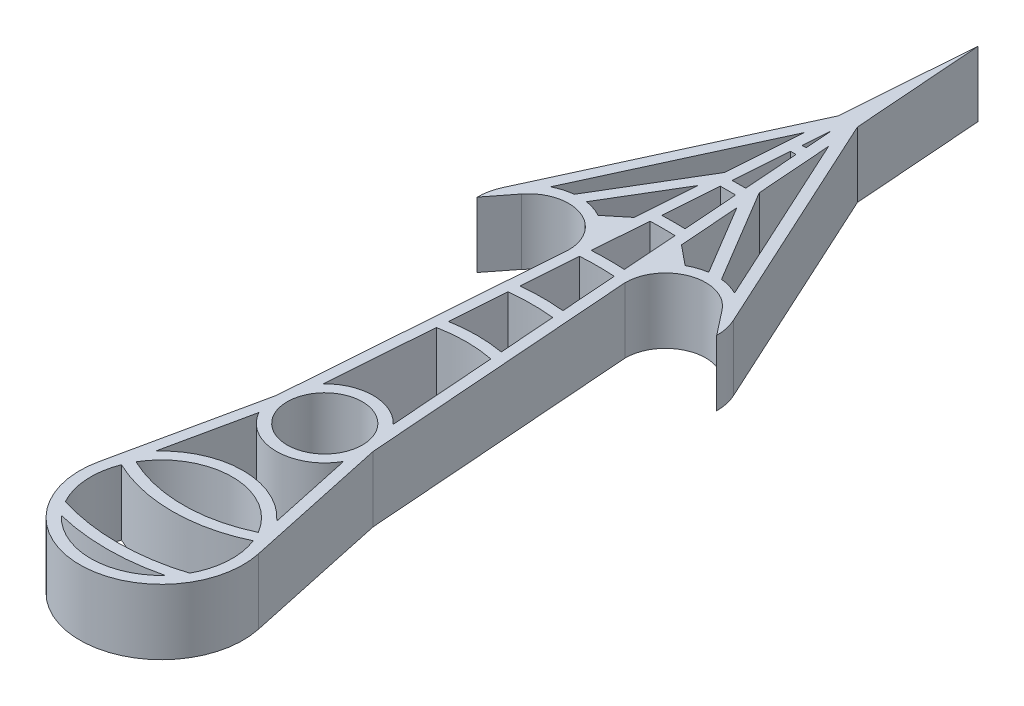
from build123d import *

# Parameters (mm, degrees)
SKETCH1_R           = 3.45
SKETCH1_R_2         = 6.5
BOSS_EXTRUDE1_DEPTH = 6
BOSS_EXTRUDE2_DEPTH = 6
BOSS_EXTRUDE4_DEPTH = 6


with BuildPart() as part:
    # Sketch1 → Boss-Extrude1 (new body)
    with BuildSketch(Plane(origin=(0, 0, 0), x_dir=(1, 0, 0), z_dir=(0, 1, 0))):
        with BuildLine():
            Line((-4.45, 0), (0, 60))
            Line((0, 60), (4.45, 0))
            Line((4.45, 0), (7.332848837, -13.425411822))
            ThreePointArc((7.332848837, -13.425411822), (0, -22.5), (-7.332848837, -13.425411822))
            Line((-7.332848837, -13.425411822), (-4.45, 0))
        make_face()
        with Locations(Location((0, 0, 0), (0, 0, 270))):
            Circle(SKETCH1_R, mode=Mode.SUBTRACT)
        with Locations(Location((0, -15, 0), (0, 0, 270))):
            Circle(SKETCH1_R_2, mode=Mode.SUBTRACT)
        with BuildLine():
            Line((-5.56959306, -9.977089176), (-3.890910153, -2.159471736))
            ThreePointArc((-3.890910153, -2.159471736), (0, -4.45), (3.890910153, -2.159471736))
            Line((3.890910153, -2.159471736), (5.56959306, -9.977089176))
            ThreePointArc((5.56959306, -9.977089176), (0, -7.5), (-5.56959306, -9.977089176))
        make_face(mode=Mode.SUBTRACT)
        with BuildLine():
            Line((-3.219404352, 3.072122332), (0, 46.479821455))
            Line((0, 46.479821455), (3.219404352, 3.072122332))
            ThreePointArc((3.219404352, 3.072122332), (0, 4.45), (-3.219404352, 3.072122332))
        make_face(mode=Mode.SUBTRACT)
    extrude(amount=BOSS_EXTRUDE1_DEPTH)

    # Sketch3 → Boss-Extrude2 (add)
    with BuildSketch(Plane(origin=(0, 0, 0), x_dir=(1, 0, 0), z_dir=(0, 1, 0))):
        with BuildLine():
            Line((-2.424610287, 13.788446793), (-2.501099218, 12.757135364))
            ThreePointArc((-2.501099218, 12.757135364), (0, 13), (2.501099218, 12.757135364))
            Line((2.501099218, 12.757135364), (2.424610287, 13.788446793))
            ThreePointArc((2.424610287, 13.788446793), (0, 14), (-2.424610287, 13.788446793))
        make_face()
        with BuildLine():
            Line((-1.971141851, 19.902627962), (-2.046283127, 18.889487165))
            ThreePointArc((-2.046283127, 18.889487165), (0, 19), (2.046283127, 18.889487165))
            Line((2.046283127, 18.889487165), (1.971141851, 19.902627962))
            ThreePointArc((1.971141851, 19.902627962), (0, 20), (-1.971141851, 19.902627962))
        make_face()
        with BuildLine():
            Line((-1.518937845, 25.999760627), (-1.593540779, 24.993878368))
            ThreePointArc((-1.593540779, 24.993878368), (0, 25.044626731), (1.593540779, 24.993878368))
            Line((1.593540779, 24.993878368), (1.518937845, 25.999760627))
            ThreePointArc((1.518937845, 25.999760627), (0, 26.044091937), (-1.518937845, 25.999760627))
        make_face()
        with BuildLine():
            Line((-1.072221947, 32.022896321), (-1.146588325, 31.020203596))
            ThreePointArc((-1.146588325, 31.020203596), (0, 31.041386823), (1.146588325, 31.020203596))
            Line((1.146588325, 31.020203596), (1.072221947, 32.022896321))
            ThreePointArc((1.072221947, 32.022896321), (0, 32.040841885), (-1.072221947, 32.022896321))
        make_face()
        with BuildLine():
            Line((-0.626517111, 38.032399738), (-0.700752129, 37.031478145))
            ThreePointArc((-0.700752129, 37.031478145), (0, 37.038107769), (0.700752129, 37.031478145))
            Line((0.700752129, 37.031478145), (0.626517111, 38.032399738))
            ThreePointArc((0.626517111, 38.032399738), (0, 38.037559774), (-0.626517111, 38.032399738))
        make_face()
        with BuildLine():
            Line((-0.181406226, 44.033894812), (-0.255560758, 43.034058423))
            ThreePointArc((-0.255560758, 43.034058423), (0, 43.034817249), (0.255560758, 43.034058423))
            Line((0.255560758, 43.034058423), (0.181406226, 44.033894812))
            ThreePointArc((0.181406226, 44.033894812), (0, 44.034268479), (-0.181406226, 44.033894812))
        make_face()
        with BuildLine():
            ThreePointArc((4.761236709, -19.425), (5.270605983, -18.804038982), (5.699506558, -18.125))
            ThreePointArc((5.699506558, -18.125), (0, -19), (-5.699506558, -18.125))
            ThreePointArc((-5.699506558, -18.125), (-5.270605983, -18.804038982), (-4.761236709, -19.425))
            ThreePointArc((-4.761236709, -19.425), (0, -20), (4.761236709, -19.425))
        make_face()
        with BuildLine():
            ThreePointArc((-5.614657158, -11.725), (-5.849946188, -12.166604581), (-6.050568155, -12.625))
            ThreePointArc((-6.050568155, -12.625), (0, -14), (6.050568155, -12.625))
            ThreePointArc((6.050568155, -12.625), (5.849946188, -12.166604581), (5.614657158, -11.725))
            ThreePointArc((5.614657158, -11.725), (0, -13), (-5.614657158, -11.725))
        make_face()
    extrude(amount=BOSS_EXTRUDE2_DEPTH)

    # Sketch5 → Boss-Extrude4 (add)
    with BuildSketch(Plane(origin=(0, 0, 0), x_dir=(1, 0, 0), z_dir=(0, 1, 0))):
        with BuildLine():
            Line((9.212671688, 27.282460114), (11, 25))
            ThreePointArc((11, 25), (10.891360502, 26.004918608), (10.570462139, 26.963400841))
            ThreePointArc((10.570462139, 26.963400841), (9.696667899, 28.24931958), (8.451309377, 29.180010468))
            ThreePointArc((8.451309377, 29.180010468), (7.63085583, 29.509197363), (6.763286857, 29.67899757))
            ThreePointArc((6.763286857, 29.67899757), (6.1879429, 29.700797107), (5.614247813, 29.652116139))
            ThreePointArc((5.614247813, 29.652116139), (4.779917704, 29.450310868), (3.996176977, 29.100192931))
            ThreePointArc((3.996176977, 29.100192931), (3.558596441, 28.82174206), (3.154345742, 28.496791317))
            ThreePointArc((3.154345742, 28.496791317), (2.463689343, 27.721817132), (1.959907971, 26.814185279))
            Line((1.959907971, 26.814185279), (2.094460046, 25))
            Line((2.094460046, 25), (2.595833333, 25))
            ThreePointArc((2.595833333, 25), (5.090697751, 28.499720488), (9.212671688, 27.282460114))
        make_face()
        with BuildLine():
            Line((1.647961612, 31.020203596), (1.749949079, 29.645091687))
            Line((1.749949079, 29.645091687), (3.154345742, 28.496791317))
            ThreePointArc((3.154345742, 28.496791317), (3.558596441, 28.82174206), (3.996176977, 29.100192931))
            Line((3.996176977, 29.100192931), (1.647961612, 31.020203596))
        make_face()
        with BuildLine():
            ThreePointArc((5.614247813, 29.652116139), (6.1879429, 29.700797107), (6.763286857, 29.67899757))
            Line((6.763286857, 29.67899757), (1.037132306, 39.256104353))
            Line((1.037132306, 39.256104353), (1.202125417, 37.031478145))
            Line((1.202125417, 37.031478145), (5.614247813, 29.652116139))
        make_face()
        with BuildLine():
            ThreePointArc((8.451309377, 29.180010468), (9.696667899, 28.24931958), (10.570462139, 26.963400841))
            Line((10.570462139, 26.963400841), (0.289570354, 49.335591342))
            Line((0.289570354, 49.335591342), (0.501373288, 46.479821455))
            Line((0.501373288, 46.479821455), (8.451309377, 29.180010468))
        make_face()
        with BuildLine():
            Line((1.749949079, 29.645091687), (1.959907971, 26.814185279))
            ThreePointArc((1.959907971, 26.814185279), (2.463689343, 27.721817132), (3.154345742, 28.496791317))
            Line((3.154345742, 28.496791317), (1.749949079, 29.645091687))
        make_face()
    boss_extrude4 = extrude(amount=BOSS_EXTRUDE4_DEPTH)

    # Mirror1: Boss-Extrude4 across plane
    add(boss_extrude4.mirror(Plane(origin=(0, 0, 0), x_dir=(0, 0, 1), z_dir=(1, 0, 0))))


solid = part.part
